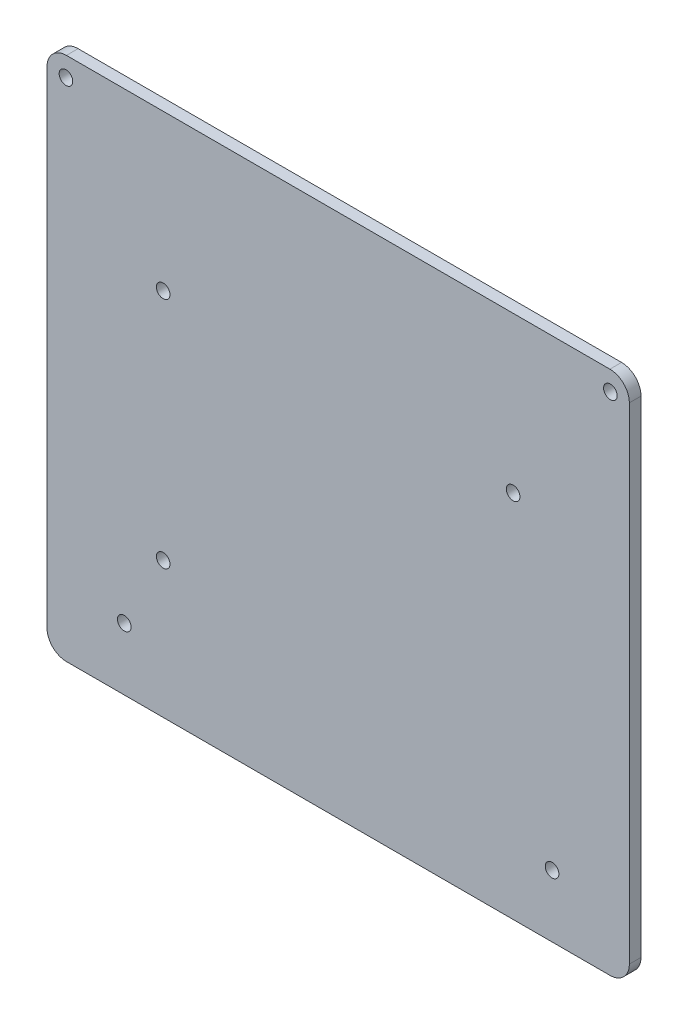
from build123d import *

# Parameters (mm, degrees)
ESQUISSE1_W        = 149.75
ESQUISSE1_H        = 135
ESQUISSE1_R        = 1.75
BOSS_EXTRU_1_DEPTH = 3
CONG_1_R           = 5


with BuildPart() as part:
    # Esquisse1 → Boss.-Extru.1 (new body)
    with BuildSketch(Plane.XY):
        Rectangle(ESQUISSE1_W, ESQUISSE1_H)
        with Locations((-70, 62.5)):
            Circle(ESQUISSE1_R, mode=Mode.SUBTRACT)
        with Locations((70, 62.5)):
            Circle(ESQUISSE1_R, mode=Mode.SUBTRACT)
        with Locations((55, -51.5)):
            Circle(ESQUISSE1_R, mode=Mode.SUBTRACT)
        with Locations((-55, -51.5)):
            Circle(ESQUISSE1_R, mode=Mode.SUBTRACT)
        with Locations((45, 27.5)):
            Circle(ESQUISSE1_R, mode=Mode.SUBTRACT)
        with Locations((-45, 27.5)):
            Circle(ESQUISSE1_R, mode=Mode.SUBTRACT)
        with Locations((-45, -32.5)):
            Circle(ESQUISSE1_R, mode=Mode.SUBTRACT)
    extrude(amount=BOSS_EXTRU_1_DEPTH)

    # Congé1
    cong_1_edges = [part.edges().sort_by_distance(p)[0] for p in [
        (-74.875, 67.5, 1.5),
        (74.875, 67.5, 1.5),
        (74.875, -67.5, 1.5),
        (-74.875, -67.5, 1.5),
    ]]
    fillet(cong_1_edges, radius=CONG_1_R)


solid = part.part
